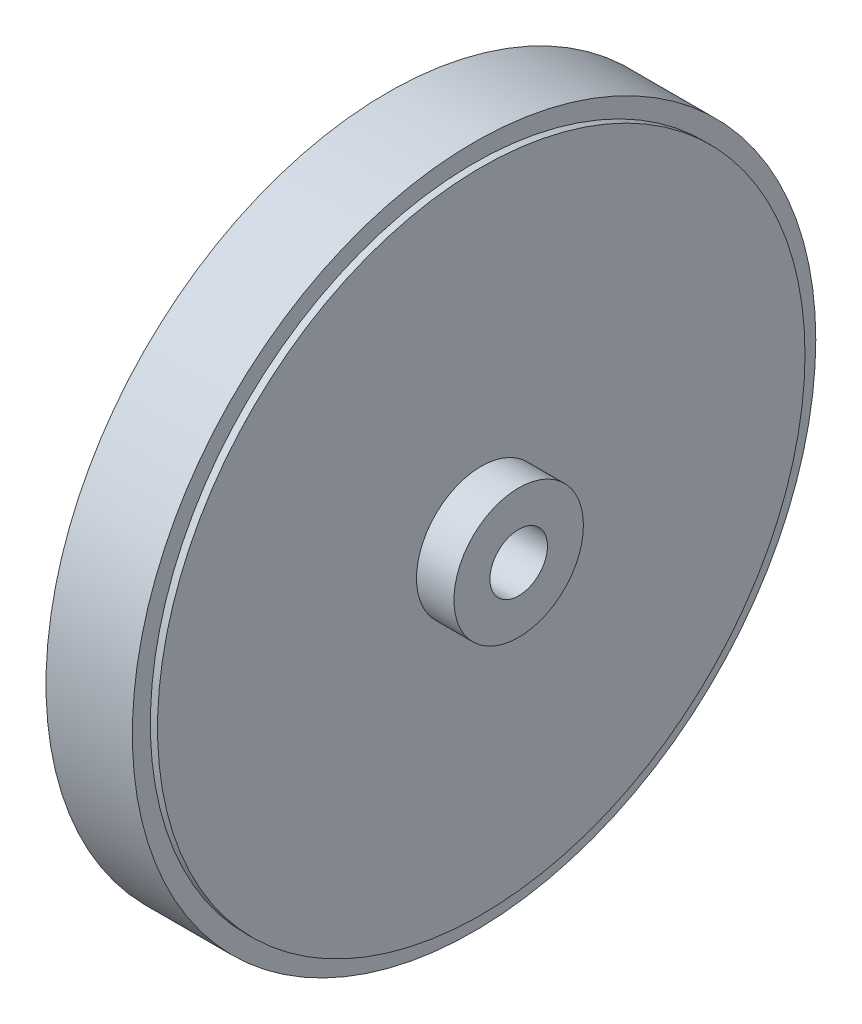
from build123d import *

# Parameters (mm, degrees)
SKETCH_2_R           = 47.5
SKETCH_2_R_2         = 4
EXTRUDE_1_DEPTH      = 12
SKETCH_3_R           = 45
SKETCH_3_R_2         = 4
EXTRUDE_2_DEPTH      = 1
EXTRUDE_2_DEPTH_BACK = 13
SKETCH_4_R           = 9
SKETCH_4_R_2         = 4
EXTRUDE_3_DEPTH      = 5.2


with BuildPart() as part:
    # 草图2 → 凸台-拉伸1 (new body)
    with BuildSketch(Plane(origin=(0, 0, 0), x_dir=(0, 0, -1), z_dir=(1, 0, 0))):
        Circle(SKETCH_2_R)
        Circle(SKETCH_2_R_2, mode=Mode.SUBTRACT)
    extrude(amount=EXTRUDE_1_DEPTH)

    # 草图3 → 凸台-拉伸2 (add, two sides)
    with BuildSketch(Plane(origin=(12, 0, 0), x_dir=(0, 0, -1), z_dir=(1, 0, 0))) as extrude_2_sk:
        Circle(SKETCH_3_R)
        Circle(SKETCH_3_R_2, mode=Mode.SUBTRACT)
    extrude(amount=EXTRUDE_2_DEPTH)
    extrude(extrude_2_sk.sketch, amount=-EXTRUDE_2_DEPTH_BACK)

    # 草图4 → 凸台-拉伸3 (add)
    with BuildSketch(Plane(origin=(13, 0, 0), x_dir=(0, 0, -1), z_dir=(1, 0, 0))):
        Circle(SKETCH_4_R)
        Circle(SKETCH_4_R_2, mode=Mode.SUBTRACT)
    extrude(amount=EXTRUDE_3_DEPTH)


solid = part.part
